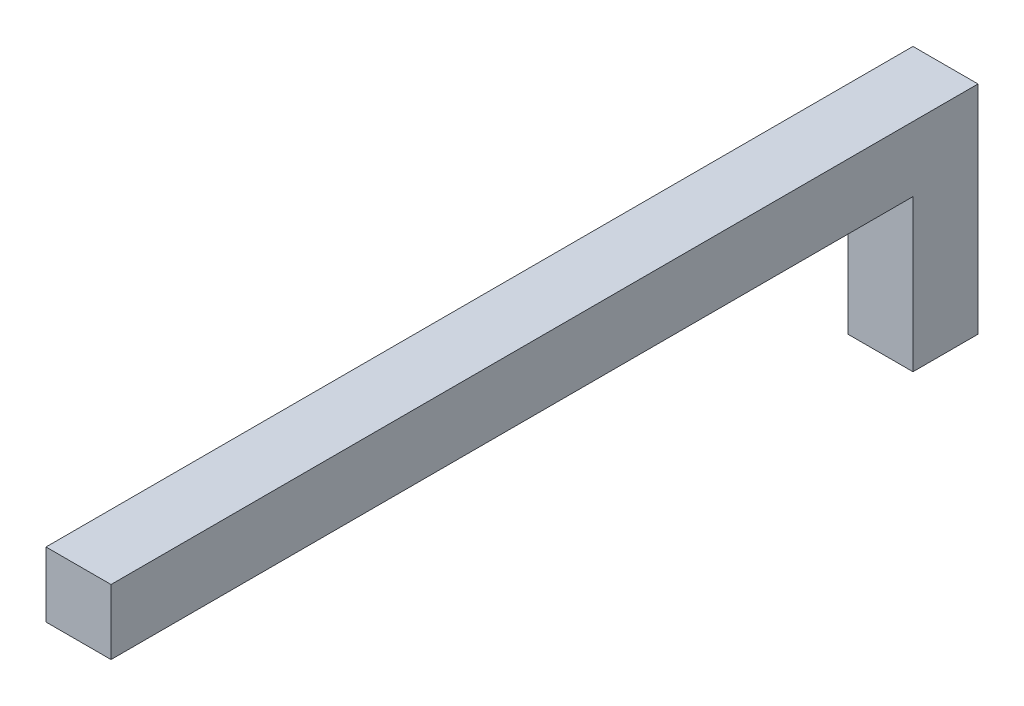
from build123d import *

# Parameters (mm, degrees)
BOSS_EXTRUDE1_DEPTH = 0.3


with BuildPart() as part:
    # Sketch1 → Boss-Extrude1 (new body, symmetric)
    with BuildSketch(Plane(origin=(0, 0, 0), x_dir=(0, 0, -1), z_dir=(1, 0, 0))):
        Polygon((-0.3, 0), (0.3, 0), (0.3, 2), (-7.7, 2), (-7.7, 1.4), (-0.3, 1.4), align=None)
    extrude(amount=BOSS_EXTRUDE1_DEPTH, both=True)


solid = part.part
